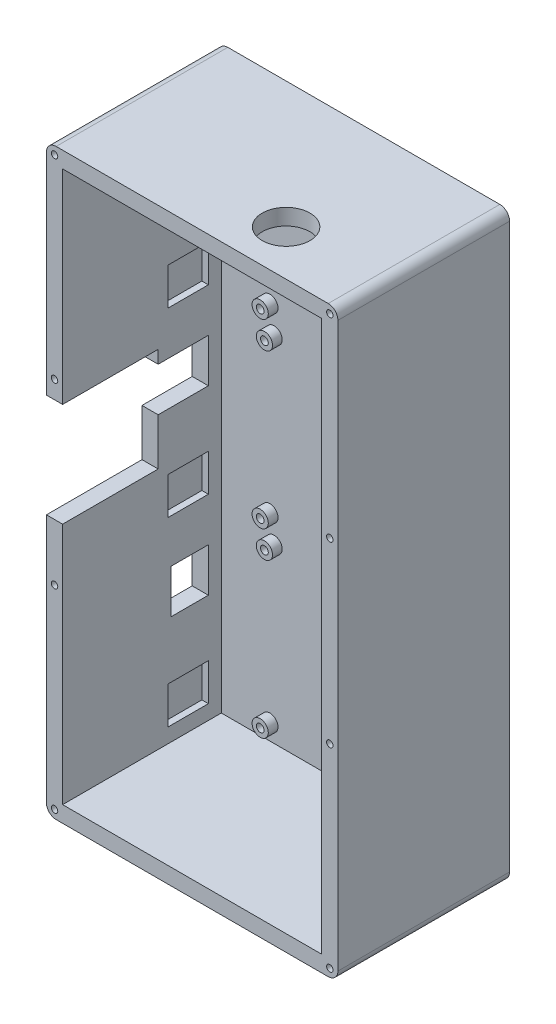
from build123d import *

# Parameters (mm, degrees)
SKETCH2_W            = 90
SKETCH2_H            = 180
BOSS_EXTRUDE1_DEPTH  = 53
SKETCH3_W            = 80
SKETCH3_H            = 170
CUT_EXTRUDE1_DEPTH   = 49
SKETCH6_R            = 2.5
BOSS_EXTRUDE2_DEPTH  = 3
M2_CLEARANCE_HOLE1_D = 2.4
SKETCH17_W           = 5
SKETCH17_H           = 32
CUT_EXTRUDE8_DEPTH   = 29.5
SKETCH19_W           = 5
SKETCH19_H           = 13.5
CUT_EXTRUDE9_DEPTH   = 45
FILLET2_R            = 3
LPATTERN1_COUNT      = 2
LPATTERN1_PITCH      = 56
LPATTERN2_COUNT      = 2
LPATTERN2_PITCH      = 56
SKETCH29_W           = 11.5
SKETCH29_H           = 13.5
CUT_EXTRUDE12_DEPTH  = 10
LPATTERN4_COUNT      = 2
LPATTERN4_PITCH      = 112
SKETCH32_W           = 12.5
SKETCH32_H           = 11.5
CUT_EXTRUDE13_DEPTH  = 2
LPATTERN5_COUNT      = 3
LPATTERN5_PITCH      = 56
SKETCH33_W           = 8
SKETCH33_H           = 10
BOSS_EXTRUDE3_DEPTH  = 5.5
CUT_EXTRUDE14_REACH  = 111.037
SKETCH34_W           = 3.5
SKETCH34_H           = 5
SKETCH35_W           = 4
SKETCH35_H           = 10
CUT_EXTRUDE15_DEPTH  = 5.5
LPATTERN6_COUNT      = 3
LPATTERN6_PITCH      = 56
SKETCH36_R           = 7.375
CUT_EXTRUDE16_DEPTH  = 10
SKETCH24_R           = 1
CUT_EXTRUDE17_DEPTH  = 114.727745076


with BuildPart() as part:
    # Sketch2 → Boss-Extrude1 (new body)
    with BuildSketch(Plane.XY):
        Rectangle(SKETCH2_W, SKETCH2_H)
    extrude(amount=BOSS_EXTRUDE1_DEPTH)

    # Sketch3 → Cut-Extrude1 (cut)
    with BuildSketch(Plane.XY.offset(53)):
        Rectangle(SKETCH3_W, SKETCH3_H)
    extrude(amount=-CUT_EXTRUDE1_DEPTH, mode=Mode.SUBTRACT)

    # Sketch6 → Boss-Extrude2 (add)
    with BuildSketch(Plane.XY.offset(4)):
        with Locations((-23.7, 24.2)):
            Circle(SKETCH6_R)
        with Locations((-25, -24)):
            Circle(SKETCH6_R)
        with Locations((27.1, 9)):
            Circle(SKETCH6_R)
        with Locations((27.1, -18.9)):
            Circle(SKETCH6_R)
    boss_extrude2 = extrude(amount=BOSS_EXTRUDE2_DEPTH)

    # M2 Clearance Hole1 (through all)
    with Locations(Plane.XY.offset(7)):
        with Locations((-23.7, 24.2), (27.1, 9), (27.1, -18.9), (-25, -24)):
            m2_clearance_hole1 = Hole(M2_CLEARANCE_HOLE1_D / 2)

    # Sketch17 → Cut-Extrude8 (cut)
    with BuildSketch(Plane.XY.offset(53)):
        with Locations((-42.5, 6)):
            Rectangle(SKETCH17_W, SKETCH17_H)
    extrude(amount=-CUT_EXTRUDE8_DEPTH, mode=Mode.SUBTRACT)

    # Sketch19 → Cut-Extrude9 (cut)
    with BuildSketch(Plane.XY.offset(53)):
        with Locations((-42.5, 11.25)):
            Rectangle(SKETCH19_W, SKETCH19_H)
    extrude(amount=-CUT_EXTRUDE9_DEPTH, mode=Mode.SUBTRACT)

    # Fillet2
    fillet2_edges = [part.edges().sort_by_distance(p)[0] for p in [
        (-45, 90, 26.5),
        (45, 90, 26.5),
        (45, -90, 26.5),
        (-45, -90, 26.5),
    ]]
    fillet(fillet2_edges, radius=FILLET2_R)

    # LPattern1: Boss-Extrude2, M2 Clearance Hole1 ×2
    with Locations(*[(0, i * LPATTERN1_PITCH, 0) for i in range(1, LPATTERN1_COUNT)]):
        add(boss_extrude2)
        add(m2_clearance_hole1, mode=Mode.SUBTRACT)

    # LPattern2: Boss-Extrude2, M2 Clearance Hole1 ×2
    with Locations(*[(0, -i * LPATTERN2_PITCH, 0) for i in range(1, LPATTERN2_COUNT)]):
        add(boss_extrude2)
        add(m2_clearance_hole1, mode=Mode.SUBTRACT)

    # Sketch29 → Cut-Extrude12 (cut)
    with BuildSketch(Plane.ZY.offset(45)):
        with Locations((13.75, 67.25)):
            Rectangle(SKETCH29_W, SKETCH29_H)
    cut_extrude12 = extrude(amount=-CUT_EXTRUDE12_DEPTH, mode=Mode.SUBTRACT)

    # LPattern4: Cut-Extrude12 ×2
    with Locations(*[(0, -i * LPATTERN4_PITCH, 0) for i in range(1, LPATTERN4_COUNT)]):
        add(cut_extrude12, mode=Mode.SUBTRACT)

    # Sketch32 → Cut-Extrude13 (cut)
    with BuildSketch(Plane(origin=(-40, 0, 0), x_dir=(0, 0, -1), z_dir=(1, 0, 0))):
        with Locations((-14.25, 37.25)):
            Rectangle(SKETCH32_W, SKETCH32_H)
    cut_extrude13 = extrude(amount=-CUT_EXTRUDE13_DEPTH, mode=Mode.SUBTRACT)

    # LPattern5: Cut-Extrude13 ×3
    with Locations(*[(0, -i * LPATTERN5_PITCH, 0) for i in range(1, LPATTERN5_COUNT)]):
        add(cut_extrude13, mode=Mode.SUBTRACT)

    # Sketch33 → Boss-Extrude3 (add)
    with BuildSketch(Plane.ZY.offset(-40)):
        with Locations((38, -35)):
            Rectangle(SKETCH33_W, SKETCH33_H)
    boss_extrude3 = extrude(amount=BOSS_EXTRUDE3_DEPTH)

    # Sketch34 → Cut-Extrude14 (cut, up to next)
    with BuildSketch(Plane.XY.offset(42), mode=Mode.PRIVATE) as cut_extrude14_sk1:
        with Locations((38.25, -35)):
            Rectangle(SKETCH34_W, SKETCH34_H)
    cut_extrude14_tool1 = extrude(cut_extrude14_sk1.sketch, amount=-CUT_EXTRUDE14_REACH, mode=Mode.PRIVATE) & part.part
    cut_extrude14 = cut_extrude14_tool1.solids().sort_by_distance((38.25, -35, 42))[0]
    add(cut_extrude14, mode=Mode.SUBTRACT)

    # Sketch35 → Cut-Extrude15 (cut)
    with BuildSketch(Plane.ZY.offset(-34.5)):
        with Locations((38, -35)):
            Rectangle(SKETCH35_W, SKETCH35_H)
    cut_extrude15 = extrude(amount=-CUT_EXTRUDE15_DEPTH, mode=Mode.SUBTRACT)

    # LPattern6: Boss-Extrude3, Cut-Extrude14, Cut-Extrude15 ×3
    with Locations(*[(0, i * LPATTERN6_PITCH, 0) for i in range(1, LPATTERN6_COUNT)]):
        add(boss_extrude3)
        add(cut_extrude14, mode=Mode.SUBTRACT)
        add(cut_extrude15, mode=Mode.SUBTRACT)

    # Sketch36 → Cut-Extrude16 (cut)
    with BuildSketch(Plane(origin=(0, 90, 0), x_dir=(1, 0, 0), z_dir=(0, 1, 0))):
        with Locations((15, -39)):
            Circle(SKETCH36_R)
    extrude(amount=-CUT_EXTRUDE16_DEPTH, mode=Mode.SUBTRACT)

    # Sketch24 → Cut-Extrude17 (cut, through all)
    with BuildSketch(Plane.XY.offset(53)):
        with Locations((-42.5, 87.5)):
            Circle(SKETCH24_R)
        with Locations((42.5, 87.5)):
            Circle(SKETCH24_R)
        with Locations((42.5, -87.5)):
            Circle(SKETCH24_R)
        with Locations((-42.5, -87.5)):
            Circle(SKETCH24_R)
        with Locations((-42.5, 27.5)):
            Circle(SKETCH24_R)
        with Locations((42.5, 27.5)):
            Circle(SKETCH24_R)
        with Locations((-42.5, -27.5)):
            Circle(SKETCH24_R)
        with Locations((42.5, -27.5)):
            Circle(SKETCH24_R)
    extrude(amount=-CUT_EXTRUDE17_DEPTH, mode=Mode.SUBTRACT)


solid = part.part
